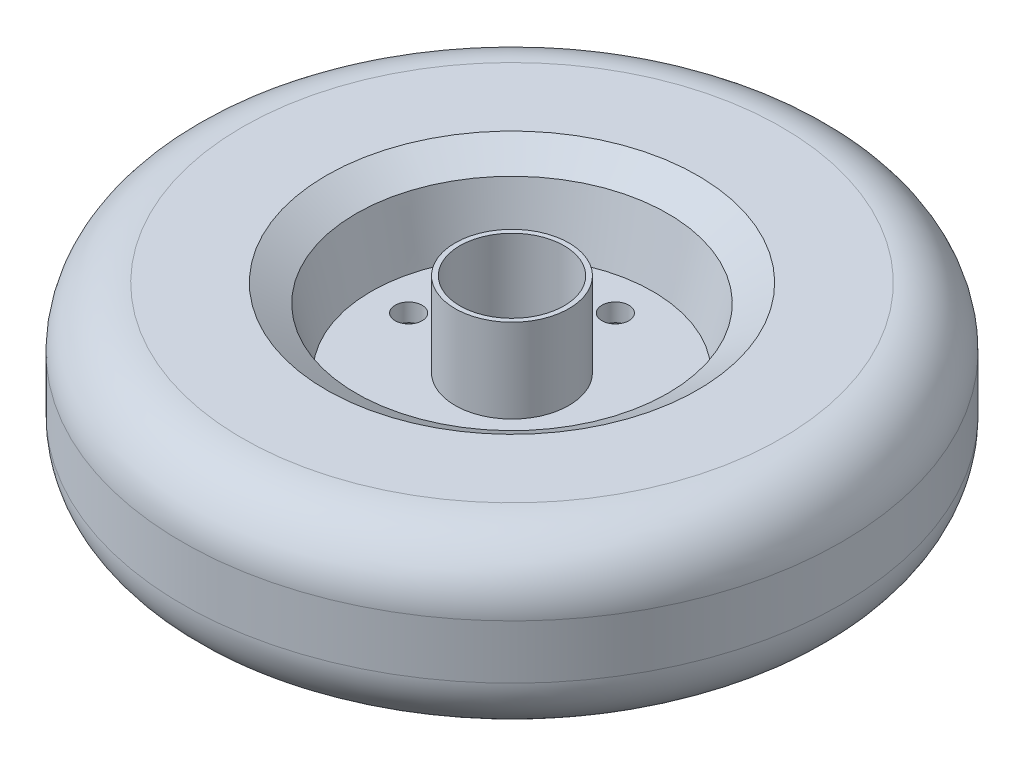
from build123d import *

# Parameters (mm, degrees)
TALADRO_DE_MARGEN_PARA_M101_D = 11
TALADRO_DE_MARGEN_PARA_M81_D  = 9
MATRIZC1_COUNT                = 4
CROQUIS8_R                    = 17.4
CORTAR_EXTRUIR2_DEPTH         = 70


with BuildPart() as part:
    # Croquis2 → Revolución1 (revolve)
    with BuildSketch(Plane.XY):
        with BuildLine():
            Line((19, 31), (0, 31))
            Line((0, 31), (0, 0))
            Line((0, 0), (110, 0))
            Line((110, 0), (110, 9))
            ThreePointArc((110, 9), (104.142135624, 23.142135624), (90, 29))
            Line((90, 29), (62, 29))
            Line((62, 29), (52, 23))
            Line((52, 23), (47, 3))
            Line((47, 3), (19, 3))
            Line((19, 3), (19, 31))
        make_face()
        with BuildLine():
            Line((110, 0), (0, 0))
            Line((0, 0), (0, -31))
            Line((0, -31), (19, -31))
            Line((19, -31), (19, -3))
            Line((19, -3), (47, -3))
            Line((47, -3), (52, -23))
            Line((52, -23), (62, -29))
            Line((62, -29), (90, -29))
            ThreePointArc((90, -29), (104.142135624, -23.142135624), (110, -9))
            Line((110, -9), (110, 0))
        make_face()
    revolve(axis=Axis((0, 64.768346902, 0), (0, -1, 0)))

    # Taladro de margen para M101 (through all)
    with Locations(Plane(origin=(0, 31, 0), x_dir=(1, 0, 0), z_dir=(0, 1, 0))):
        with Locations((0, 0)):
            Hole(TALADRO_DE_MARGEN_PARA_M101_D / 2)

    # Taladro de margen para M81 (through all)
    with Locations(Plane(origin=(0, 3, 0), x_dir=(1, 0, 0), z_dir=(0, 1, 0))):
        with Locations((0, 34.5)):
            taladro_de_margen_para_m81 = Hole(TALADRO_DE_MARGEN_PARA_M81_D / 2)

    # MatrizC1: Taladro de margen para M81 ×4 about axis
    matrizc1_axis = Axis((0, 0, 0), (0, 1, 0))
    for i in range(1, MATRIZC1_COUNT):
        add(taladro_de_margen_para_m81.rotate(matrizc1_axis, i * 360 / MATRIZC1_COUNT), mode=Mode.SUBTRACT)

    # Croquis8 → Cortar-Extruir2 (cut)
    with BuildSketch(Plane(origin=(0, 31, 0), x_dir=(1, 0, 0), z_dir=(0, 1, 0))):
        Circle(CROQUIS8_R)
    extrude(amount=-CORTAR_EXTRUIR2_DEPTH, mode=Mode.SUBTRACT)


solid = part.part
